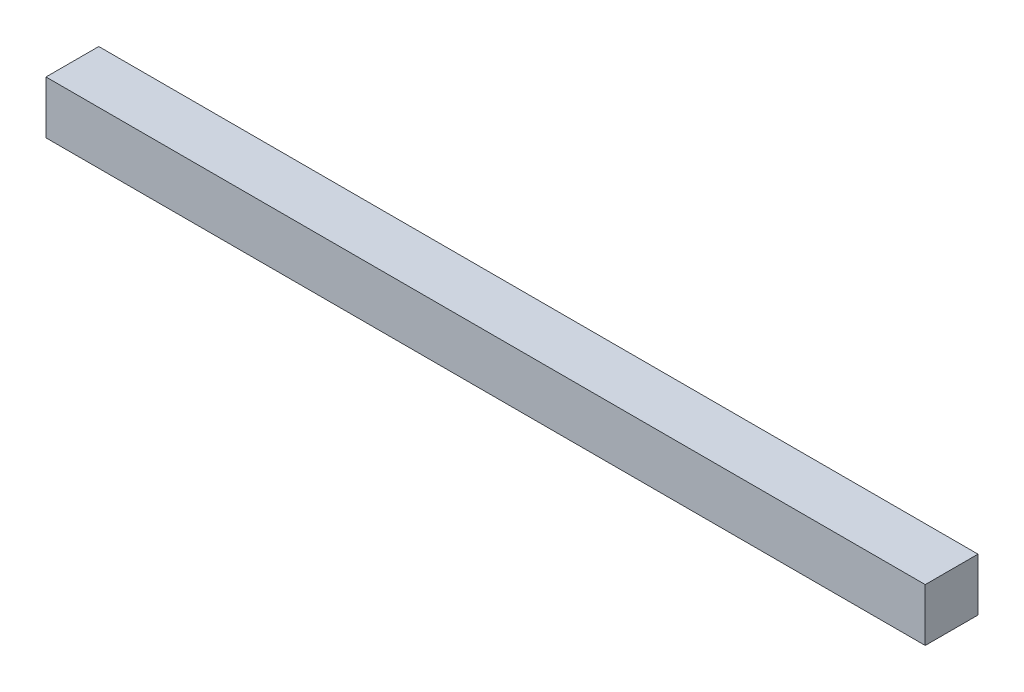
from build123d import *

# Parameters (mm, degrees)
SKETCH_1_W      = 30
SKETCH_1_H      = 30
EXTRUDE_1_DEPTH = 500


with BuildPart() as part:
    # 스케치1 → 보스-돌출1 (new body)
    with BuildSketch(Plane(origin=(0, 0, 0), x_dir=(0, 0, -1), z_dir=(1, 0, 0))):
        Rectangle(SKETCH_1_W, SKETCH_1_H)
    extrude(amount=EXTRUDE_1_DEPTH)


solid = part.part
